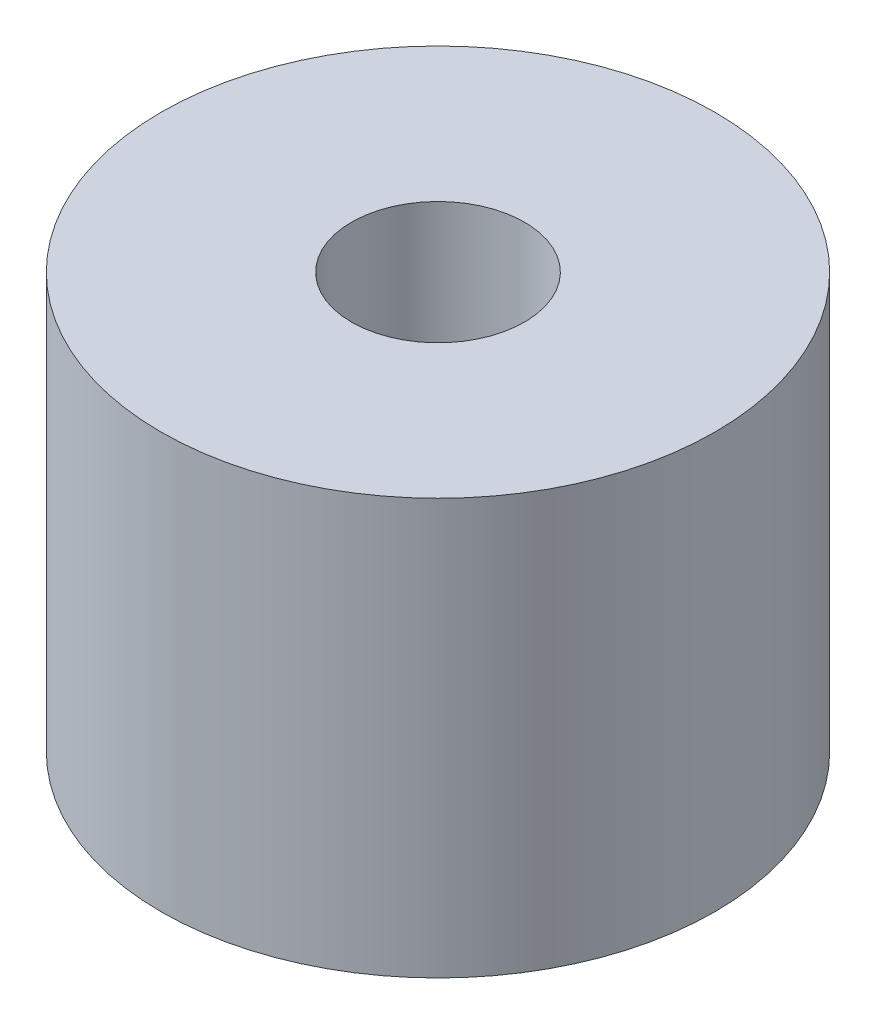
from build123d import *

# Parameters (mm, degrees)
SKETCH1_R                   = 12.7
BOSS_EXTRUDE1_DEPTH         = 19.05
TAP_DRILL_FOR_3_8_16_TAP1_D = 7.9375


with BuildPart() as part:
    # Sketch1 → Boss-Extrude1 (new body)
    with BuildSketch(Plane(origin=(0, 0, 0), x_dir=(1, 0, 0), z_dir=(0, 1, 0))):
        Circle(SKETCH1_R)
    extrude(amount=BOSS_EXTRUDE1_DEPTH)

    # Tap Drill for 3/8-16 Tap1 (through all)
    with Locations(Plane(origin=(0, 19.05, 0), x_dir=(1, 0, 0), z_dir=(0, 1, 0))):
        with Locations((0, 0)):
            Hole(TAP_DRILL_FOR_3_8_16_TAP1_D / 2)


solid = part.part
